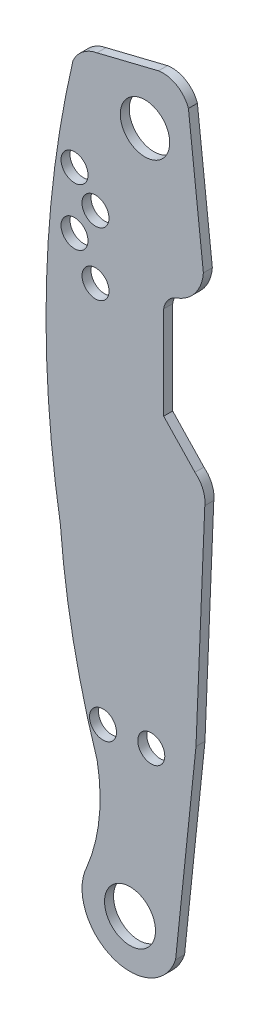
from build123d import *

# Parameters (mm, degrees)
SKETCH1_R           = 2.159
SKETCH1_R_2         = 1.143
SKETCH1_R_3         = 2.0955
BOSS_EXTRUDE1_DEPTH = 0.381


with BuildPart() as part:
    # Sketch1 → Boss-Extrude1 (new body, symmetric)
    with BuildSketch(Plane.XY):
        with BuildLine():
            Line((74.009533162, 2.524763773), (72.281998937, -13.985236227))
            ThreePointArc((72.281998937, -13.985236227), (66.894838719, -16.481573981), (64.766369935, -10.938757185))
            ThreePointArc((64.766369935, -10.938757185), (65.80913713, -6.8614285), (65.635785401, -2.656440771))
            ThreePointArc((65.635785401, -2.656440771), (63.616027596, 5.10567878), (62.526786778, 13.051965708))
            ThreePointArc((62.526786778, 13.051965708), (61.351286871, 30.387313841), (63.589596905, 47.617695819))
            ThreePointArc((63.589596905, 47.617695819), (64.412502938, 48.666218898), (65.627533162, 49.214193845))
            Line((65.627533162, 49.214193845), (70.834533162, 50.498790171))
            ThreePointArc((70.834533162, 50.498790171), (72.374643438, 50.21510876), (73.370794631, 49.006763773))
            Line((73.370794631, 49.006763773), (74.635112814, 37.576763773))
            ThreePointArc((74.635112814, 37.576763773), (73.946841775, 35.757603322), (72.379792613, 34.605466744))
            ThreePointArc((72.379792613, 34.605466744), (71.641962058, 34.084204846), (71.274872248, 33.258763773))
            Line((71.274872248, 33.258763773), (71.274872248, 25.384763773))
            Line((71.274872248, 25.384763773), (73.922374141, 22.590763773))
            ThreePointArc((73.922374141, 22.590763773), (74.599970213, 21.681643486), (74.757378227, 20.558763773))
            Line((74.757378227, 20.558763773), (74.009533162, 2.524763773))
        make_face()
        with Locations((68.421533162, -12.715236227)):
            Circle(SKETCH1_R, mode=Mode.SUBTRACT)
        with Locations((70.224933162, 0.492763773)):
            Circle(SKETCH1_R_2, mode=Mode.SUBTRACT)
        with Locations((66.135533162, 0.202809344)):
            Circle(SKETCH1_R_2, mode=Mode.SUBTRACT)
        with Locations((65.500533162, 32.242763773)):
            Circle(SKETCH1_R_2, mode=Mode.SUBTRACT)
        with Locations((65.500533162, 37.576763773)):
            Circle(SKETCH1_R_2, mode=Mode.SUBTRACT)
        with Locations((69.691533162, 45.704763773)):
            Circle(SKETCH1_R_3, mode=Mode.SUBTRACT)
        with Locations((63.722533162, 39.862763773)):
            Circle(SKETCH1_R_2, mode=Mode.SUBTRACT)
        with Locations((63.722533162, 35.036763773)):
            Circle(SKETCH1_R_2, mode=Mode.SUBTRACT)
    extrude(amount=BOSS_EXTRUDE1_DEPTH, both=True)


solid = part.part
